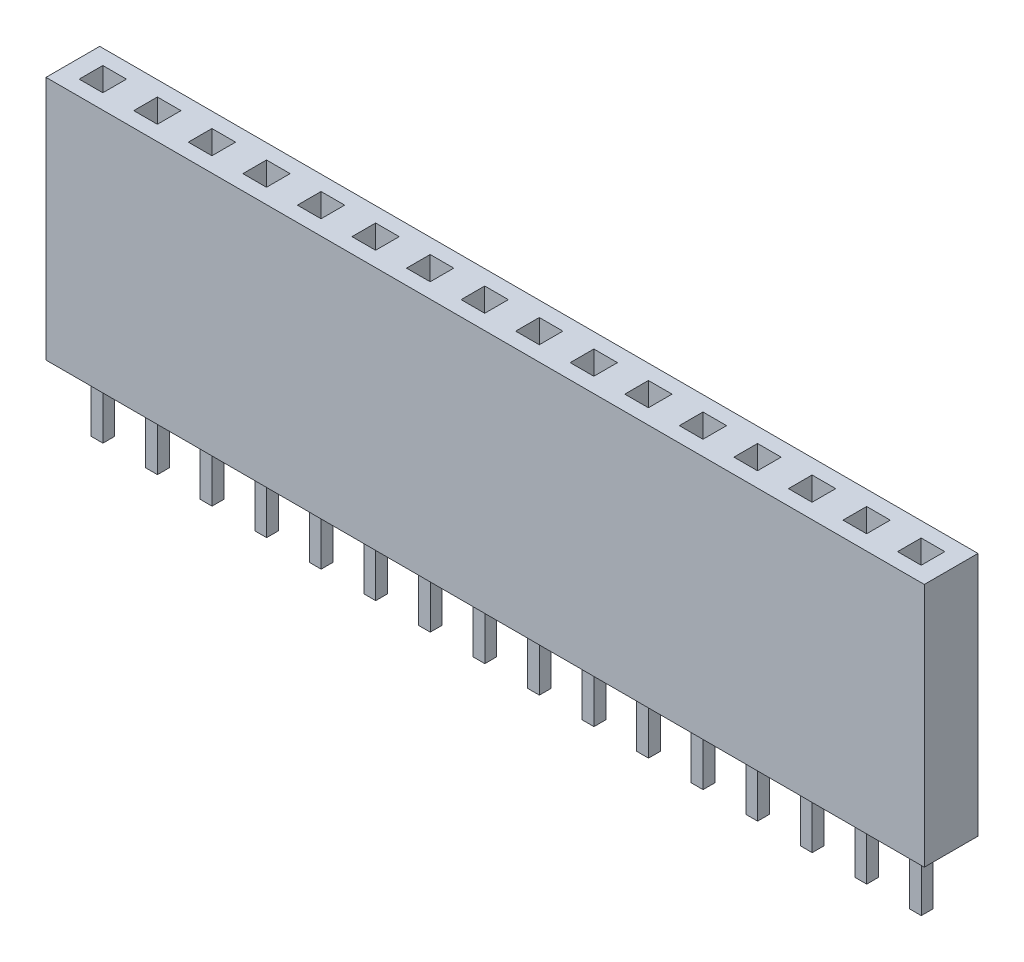
from build123d import *

# Parameters (mm, degrees)
SKETCH1_W              = 40.89
SKETCH1_H              = 11.4
BOSS_EXTRUDE1_DEPTH    = 1.25
SKETCH2_W              = 1.1
SKETCH2_H              = 1.1
CUT_EXTRUDE1_DEPTH     = 43.46780663
SKETCH3_W              = 40.89
SKETCH3_H              = 2.5
BOSS_EXTRUDE2_DEPTH    = 1
SKETCH4_W              = 0.55
SKETCH4_H              = 0.55
BOSS_EXTRUDE3_DEPTH    = 3
BOSS_EXTRUDE3_2_DEPTH  = 3
BOSS_EXTRUDE3_3_DEPTH  = 3
BOSS_EXTRUDE3_4_DEPTH  = 3
BOSS_EXTRUDE3_5_DEPTH  = 3
BOSS_EXTRUDE3_6_DEPTH  = 3
BOSS_EXTRUDE3_7_DEPTH  = 3
BOSS_EXTRUDE3_8_DEPTH  = 3
BOSS_EXTRUDE3_9_DEPTH  = 3
BOSS_EXTRUDE3_10_DEPTH = 3
BOSS_EXTRUDE3_11_DEPTH = 3
BOSS_EXTRUDE3_12_DEPTH = 3
BOSS_EXTRUDE3_13_DEPTH = 3
BOSS_EXTRUDE3_14_DEPTH = 3
BOSS_EXTRUDE3_15_DEPTH = 3
BOSS_EXTRUDE3_16_DEPTH = 3


with BuildPart() as part:
    # Sketch1 → Boss-Extrude1 (new, symmetric)
    with BuildSketch(Plane.XY):
        with Locations((20.445, 5.7)):
            Rectangle(SKETCH1_W, SKETCH1_H)
    extrude(amount=BOSS_EXTRUDE1_DEPTH, both=True)

    # Sketch2 → Cut-Extrude1 (cut, through all)
    with BuildSketch(Plane.XZ):
        with Locations((3.935, 0)):
            Rectangle(SKETCH2_W, SKETCH2_H)
        with Locations((1.395, 0)):
            Rectangle(SKETCH2_W, SKETCH2_H)
        with Locations((6.475, 0)):
            Rectangle(SKETCH2_W, SKETCH2_H)
        with Locations((9.015, 0)):
            Rectangle(SKETCH2_W, SKETCH2_H)
        with Locations((11.555, 0)):
            Rectangle(SKETCH2_W, SKETCH2_H)
        with Locations((14.095, 0)):
            Rectangle(SKETCH2_W, SKETCH2_H)
        with Locations((16.635, 0)):
            Rectangle(SKETCH2_W, SKETCH2_H)
        with Locations((19.175, 0)):
            Rectangle(SKETCH2_W, SKETCH2_H)
        with Locations((21.715, 0)):
            Rectangle(SKETCH2_W, SKETCH2_H)
        with Locations((24.255, 0)):
            Rectangle(SKETCH2_W, SKETCH2_H)
        with Locations((26.795, 0)):
            Rectangle(SKETCH2_W, SKETCH2_H)
        with Locations((29.335, 0)):
            Rectangle(SKETCH2_W, SKETCH2_H)
        with Locations((31.875, 0)):
            Rectangle(SKETCH2_W, SKETCH2_H)
        with Locations((34.415, 0)):
            Rectangle(SKETCH2_W, SKETCH2_H)
        with Locations((36.955, 0)):
            Rectangle(SKETCH2_W, SKETCH2_H)
        with Locations((39.495, 0)):
            Rectangle(SKETCH2_W, SKETCH2_H)
    extrude(amount=-CUT_EXTRUDE1_DEPTH, mode=Mode.SUBTRACT)

    # Sketch3 → Boss-Extrude2 (add)
    with BuildSketch(Plane.XZ):
        with Locations((20.445, 0)):
            Rectangle(SKETCH3_W, SKETCH3_H)
    extrude(amount=-BOSS_EXTRUDE2_DEPTH)


with BuildPart() as body_2:
    # Sketch4 → Boss-Extrude3 (new body)
    with BuildSketch(Plane.XZ):
        with Locations((1.4, 0)):
            Rectangle(SKETCH4_W, SKETCH4_H)
    extrude(amount=BOSS_EXTRUDE3_DEPTH)


with BuildPart() as body_3:
    # Sketch4 → Boss-Extrude3 2 (new body)
    with BuildSketch(Plane.XZ):
        with Locations((3.94, 0)):
            Rectangle(SKETCH4_W, SKETCH4_H)
    extrude(amount=BOSS_EXTRUDE3_2_DEPTH)


with BuildPart() as body_4:
    # Sketch4 → Boss-Extrude3 3 (new body)
    with BuildSketch(Plane.XZ):
        with Locations((6.48, 0)):
            Rectangle(SKETCH4_W, SKETCH4_H)
    extrude(amount=BOSS_EXTRUDE3_3_DEPTH)


with BuildPart() as body_5:
    # Sketch4 → Boss-Extrude3 4 (new body)
    with BuildSketch(Plane.XZ):
        with Locations((9.02, 0)):
            Rectangle(SKETCH4_W, SKETCH4_H)
    extrude(amount=BOSS_EXTRUDE3_4_DEPTH)


with BuildPart() as body_6:
    # Sketch4 → Boss-Extrude3 5 (new body)
    with BuildSketch(Plane.XZ):
        with Locations((11.56, 0)):
            Rectangle(SKETCH4_W, SKETCH4_H)
    extrude(amount=BOSS_EXTRUDE3_5_DEPTH)


with BuildPart() as body_7:
    # Sketch4 → Boss-Extrude3 6 (new body)
    with BuildSketch(Plane.XZ):
        with Locations((14.1, 0)):
            Rectangle(SKETCH4_W, SKETCH4_H)
    extrude(amount=BOSS_EXTRUDE3_6_DEPTH)


with BuildPart() as body_8:
    # Sketch4 → Boss-Extrude3 7 (new body)
    with BuildSketch(Plane.XZ):
        with Locations((16.64, 0)):
            Rectangle(SKETCH4_W, SKETCH4_H)
    extrude(amount=BOSS_EXTRUDE3_7_DEPTH)


with BuildPart() as body_9:
    # Sketch4 → Boss-Extrude3 8 (new body)
    with BuildSketch(Plane.XZ):
        with Locations((19.18, 0)):
            Rectangle(SKETCH4_W, SKETCH4_H)
    extrude(amount=BOSS_EXTRUDE3_8_DEPTH)


with BuildPart() as body_10:
    # Sketch4 → Boss-Extrude3 9 (new body)
    with BuildSketch(Plane.XZ):
        with Locations((21.72, 0)):
            Rectangle(SKETCH4_W, SKETCH4_H)
    extrude(amount=BOSS_EXTRUDE3_9_DEPTH)


with BuildPart() as body_11:
    # Sketch4 → Boss-Extrude3 10 (new body)
    with BuildSketch(Plane.XZ):
        with Locations((24.26, 0)):
            Rectangle(SKETCH4_W, SKETCH4_H)
    extrude(amount=BOSS_EXTRUDE3_10_DEPTH)


with BuildPart() as body_12:
    # Sketch4 → Boss-Extrude3 11 (new body)
    with BuildSketch(Plane.XZ):
        with Locations((26.8, 0)):
            Rectangle(SKETCH4_W, SKETCH4_H)
    extrude(amount=BOSS_EXTRUDE3_11_DEPTH)


with BuildPart() as body_13:
    # Sketch4 → Boss-Extrude3 12 (new body)
    with BuildSketch(Plane.XZ):
        with Locations((29.34, 0)):
            Rectangle(SKETCH4_W, SKETCH4_H)
    extrude(amount=BOSS_EXTRUDE3_12_DEPTH)


with BuildPart() as body_14:
    # Sketch4 → Boss-Extrude3 13 (new body)
    with BuildSketch(Plane.XZ):
        with Locations((31.88, 0)):
            Rectangle(SKETCH4_W, SKETCH4_H)
    extrude(amount=BOSS_EXTRUDE3_13_DEPTH)


with BuildPart() as body_15:
    # Sketch4 → Boss-Extrude3 14 (new body)
    with BuildSketch(Plane.XZ):
        with Locations((34.42, 0)):
            Rectangle(SKETCH4_W, SKETCH4_H)
    extrude(amount=BOSS_EXTRUDE3_14_DEPTH)


with BuildPart() as body_16:
    # Sketch4 → Boss-Extrude3 15 (new body)
    with BuildSketch(Plane.XZ):
        with Locations((36.96, 0)):
            Rectangle(SKETCH4_W, SKETCH4_H)
    extrude(amount=BOSS_EXTRUDE3_15_DEPTH)


with BuildPart() as body_17:
    # Sketch4 → Boss-Extrude3 16 (new body)
    with BuildSketch(Plane.XZ):
        with Locations((39.5, 0)):
            Rectangle(SKETCH4_W, SKETCH4_H)
    extrude(amount=BOSS_EXTRUDE3_16_DEPTH)


solid = Compound([part.part, body_2.part, body_3.part, body_4.part, body_5.part, body_6.part, body_7.part, body_8.part, body_9.part, body_10.part, body_11.part, body_12.part, body_13.part, body_14.part, body_15.part, body_16.part, body_17.part])
